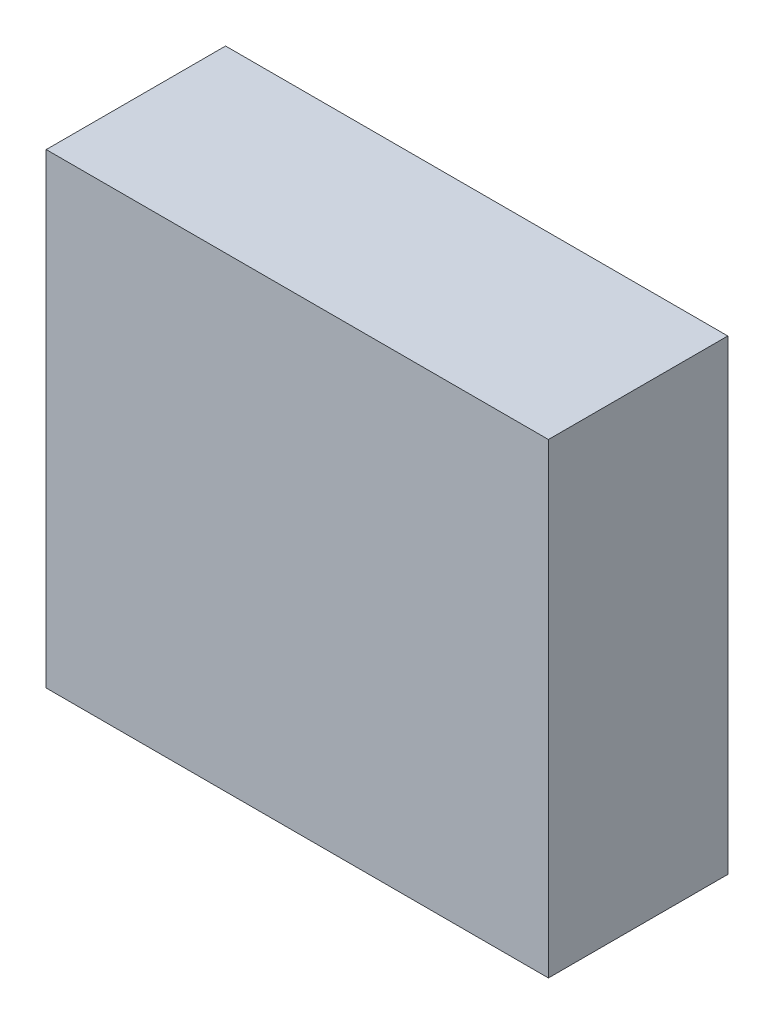
from build123d import *

# Parameters (mm, degrees)
SKETCH_1_W      = 70
SKETCH_1_H      = 65
EXTRUDE_1_DEPTH = 25


with BuildPart() as part:
    # 草图1 → 凸台-拉伸1 (new body)
    with BuildSketch(Plane.XY):
        Rectangle(SKETCH_1_W, SKETCH_1_H)
    extrude(amount=EXTRUDE_1_DEPTH)


solid = part.part
